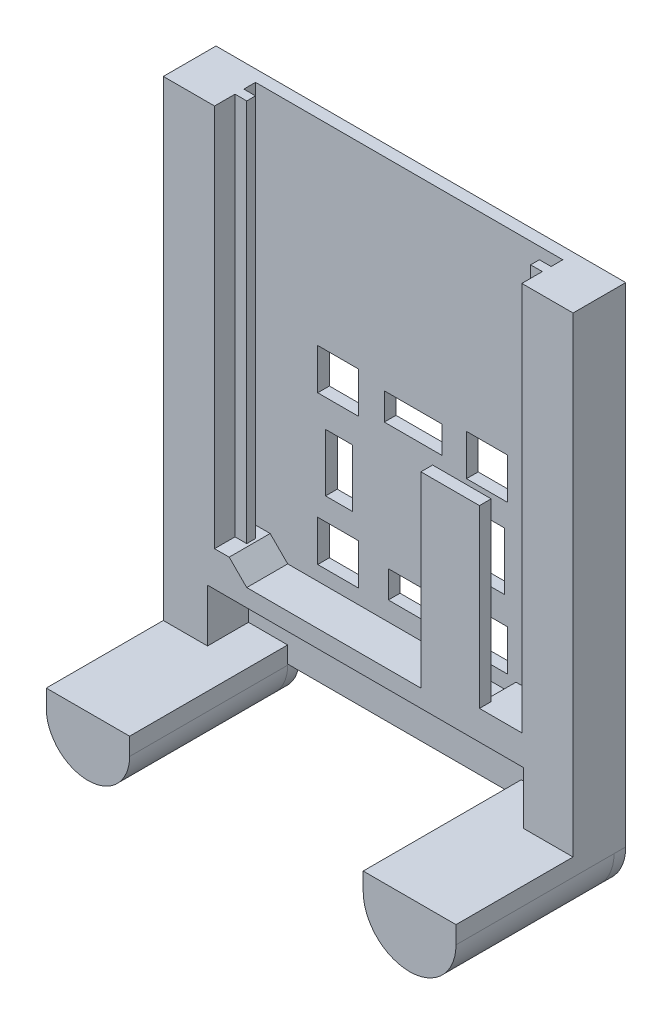
from build123d import *

# Parameters (mm, degrees)
BOSS_EXTRUDE1_DEPTH = 7
SKETCH3_W           = 1.5
SKETCH3_H           = 65.5
BOSS_EXTRUDE2_DEPTH = 2
SKETCH4_W           = 1.5
SKETCH4_H           = 66.5
BOSS_EXTRUDE3_DEPTH = 2
SKETCH7_W           = 10
SKETCH7_H           = 33.446163333
BOSS_EXTRUDE6_DEPTH = 2
BOSS_EXTRUDE7_DEPTH = 2
BOSS_EXTRUDE8_DEPTH = 20
SKETCH15_W          = 7
SKETCH15_H          = 7
CUT_EXTRUDE4_DEPTH  = 2
SKETCH16_W          = 4.633871769
SKETCH16_H          = 9.84697751
SKETCH16_W_2        = 9.84697751
SKETCH16_H_2        = 4.63387177
SKETCH16_H_3        = 9.846977511
CUT_EXTRUDE5_DEPTH  = 2


with BuildPart() as part:
    # Sketch2 → Boss-Extrude1 (new body)
    with BuildSketch(Plane.XY):
        with BuildLine():
            Line((70, 0), (70, 71.493036289))
            Line((70, 71.493036289), (61.25, 71.493036289))
            Line((61.25, 71.493036289), (61.25, 4.993036289))
            Line((61.25, 4.993036289), (53.25, 4.993036289))
            Line((53.25, 4.993036289), (51.365136631, 2.993036289))
            Line((51.365136631, 2.993036289), (14.25, 2.993036289))
            Line((14.25, 2.993036289), (11.25, 5.993036289))
            Line((11.25, 5.993036289), (8.75, 5.993036289))
            Line((8.75, 5.993036289), (8.75, 71.493036289))
            Line((8.75, 71.493036289), (0, 71.493036289))
            Line((0, 71.493036289), (0, 0))
            Line((0, 0), (0, -12))
            ThreePointArc((0, -12), (7.120138309, -19.120138309), (14.240276619, -12))
            Line((14.240276619, -12), (14.240276619, -9))
            Line((14.240276619, -9), (7.551059866, -9))
            Line((7.551059866, -9), (7.551059866, 0))
            Line((7.551059866, 0), (61.551059866, 0))
            Line((61.551059866, 0), (61.551059866, -9))
            Line((61.551059866, -9), (54.143055629, -9))
            Line((54.143055629, -9), (54.143055629, -12))
            ThreePointArc((54.143055629, -12), (62.071527814, -19.928472186), (70, -12))
            Line((70, -12), (70, 0))
        make_face()
    extrude(amount=BOSS_EXTRUDE1_DEPTH)

    # Sketch3 → Boss-Extrude2 (add)
    with BuildSketch(Plane(origin=(8.75, 0, 0), x_dir=(0, 0, -1), z_dir=(1, 0, 0))):
        with Locations((-2.75, 38.743036289)):
            Rectangle(SKETCH3_W, SKETCH3_H)
    extrude(amount=BOSS_EXTRUDE2_DEPTH)

    # Sketch4 → Boss-Extrude3 (add)
    with BuildSketch(Plane.ZY.offset(-61.25)):
        with Locations((2.75, 38.243036289)):
            Rectangle(SKETCH4_W, SKETCH4_H)
    extrude(amount=BOSS_EXTRUDE3_DEPTH)

    # Sketch7 → Boss-Extrude6 (add)
    with BuildSketch(Plane.XY.offset(7)):
        with Locations((49.00753408, 18.276918333)):
            Rectangle(SKETCH7_W, SKETCH7_H)
    extrude(amount=-BOSS_EXTRUDE6_DEPTH)

    # Sketch8 → Boss-Extrude7 (add)
    with BuildSketch(Plane(origin=(0, 0, 0), x_dir=(-1, 0, 0), z_dir=(0, 0, -1))):
        with BuildLine():
            Line((-70, 71.493036289), (0, 71.493036289))
            Line((0, 71.493036289), (0, -11.821263414))
            ThreePointArc((0, -11.821263414), (-7.120138309, -19.120135173), (-14.240276619, -11.821263414))
            Line((-14.240276619, -11.821263414), (-54.143055629, -11.821263414))
            ThreePointArc((-54.143055629, -11.821263414), (-61.981146501, -19.928975841), (-70, -12))
            Line((-70, -12), (-70, 71.493036289))
        make_face()
    extrude(amount=BOSS_EXTRUDE7_DEPTH)

    # Sketch14 → Boss-Extrude8 (add)
    with BuildSketch(Plane.XY.offset(7)):
        with BuildLine():
            Line((14.240276619, -12), (14.240276619, -9))
            Line((14.240276619, -9), (0, -9))
            Line((0, -9), (0, -12))
            ThreePointArc((0, -12), (7.120138309, -19.120138309), (14.240276619, -12))
        make_face()
        with BuildLine():
            Line((54.143055629, -12), (54.143055629, -9))
            Line((54.143055629, -9), (70, -9))
            Line((70, -9), (70, -12))
            ThreePointArc((70, -12), (62.071527814, -19.928472186), (54.143055629, -12))
        make_face()
    extrude(amount=BOSS_EXTRUDE8_DEPTH)

    # Sketch15 → Cut-Extrude4 (cut)
    with BuildSketch(Plane(origin=(0, 0, -2), x_dir=(-1, 0, 0), z_dir=(0, 0, -1))):
        with Locations((-48.294388032, 8.963448797)):
            Rectangle(SKETCH15_W, SKETCH15_H)
        with Locations((-48.294388032, 34.373848797)):
            Rectangle(SKETCH15_W, SKETCH15_H)
        with Locations((-22.874388032, 8.963448797)):
            Rectangle(SKETCH15_W, SKETCH15_H)
        with Locations((-22.874388032, 34.373848797)):
            Rectangle(SKETCH15_W, SKETCH15_H)
    extrude(amount=-CUT_EXTRUDE4_DEPTH, mode=Mode.SUBTRACT)

    # Sketch16 → Cut-Extrude5 (cut)
    with BuildSketch(Plane(origin=(0, 0, -2), x_dir=(-1, 0, 0), z_dir=(0, 0, -1))):
        with Locations((-49.007648907, 21.901962869)):
            Rectangle(SKETCH16_W, SKETCH16_H)
        with Locations((-35.672375834, 34.542330615)):
            Rectangle(SKETCH16_W_2, SKETCH16_H_2)
        with Locations((-36.367281161, 8.566689797)):
            Rectangle(SKETCH16_W_2, SKETCH16_H_2)
        with Locations((-23.032008088, 21.207057543)):
            Rectangle(SKETCH16_W, SKETCH16_H_3)
    extrude(amount=-CUT_EXTRUDE5_DEPTH, mode=Mode.SUBTRACT)


solid = part.part
